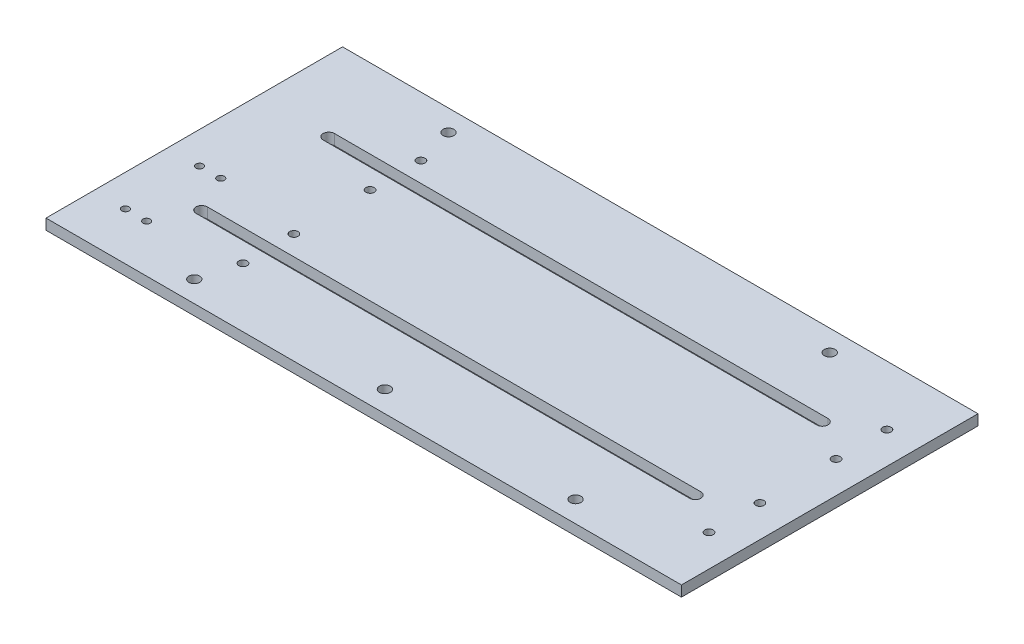
from build123d import *

# Parameters (mm, degrees)
SKETCH1_W                  = 381
SKETCH1_H                  = 177.8
PLATE_DEPTH                = 6.35
SKETCH4_R                  = 3.2639
CHASSISMOUNTINGHOLES_DEPTH = 6.35
SKETCH5_R                  = 2.5019
LEADSCREWGUIDEMOUNTS_DEPTH = 6.35
SKETCH6_R                  = 2.15265
LEADSCREWMOTORMOUNT_DEPTH  = 6.35
SKETCH8_R                  = 3.2639
CUT_EXTRUDE2_DEPTH         = 7.35
CUT_EXTRUDE4_DEPTH         = 7.35


with BuildPart() as part:
    # Sketch1 → Plate (new body)
    with BuildSketch(Plane(origin=(0, 0, 0), x_dir=(1, 0, 0), z_dir=(0, 1, 0))):
        Rectangle(SKETCH1_W, SKETCH1_H)
    extrude(amount=PLATE_DEPTH)

    # Sketch4 → ChassisMountingHoles (cut)
    with BuildSketch(Plane.XZ):
        with Locations((0, 76.2)):
            Circle(SKETCH4_R)
        with Locations((-114.3, 76.2)):
            Circle(SKETCH4_R)
        with Locations((114.3, 76.2)):
            Circle(SKETCH4_R)
        with Locations((-114.3, -76.2)):
            Circle(SKETCH4_R)
        with Locations((114.3, -76.2)):
            Circle(SKETCH4_R)
    extrude(amount=-CHASSISMOUNTINGHOLES_DEPTH, mode=Mode.SUBTRACT)

    # Sketch5 → LeadScrewGuideMounts (cut)
    with BuildSketch(Plane.XZ):
        with Locations((171.45, 53.34)):
            Circle(SKETCH5_R)
        with Locations((171.45, 22.86)):
            Circle(SKETCH5_R)
        with Locations((-107.95, 53.34)):
            Circle(SKETCH5_R)
        with Locations((-107.95, 22.86)):
            Circle(SKETCH5_R)
        with Locations((171.45, -53.34)):
            Circle(SKETCH5_R)
        with Locations((171.45, -22.86)):
            Circle(SKETCH5_R)
        with Locations((-107.95, -22.86)):
            Circle(SKETCH5_R)
        with Locations((-107.95, -53.34)):
            Circle(SKETCH5_R)
    extrude(amount=-LEADSCREWGUIDEMOUNTS_DEPTH, mode=Mode.SUBTRACT)

    # Sketch6 → LeadScrewMotorMount (cut)
    with BuildSketch(Plane.XZ):
        with Locations((-171.45, 60.325)):
            Circle(SKETCH6_R)
        with Locations((-158.75, 60.325)):
            Circle(SKETCH6_R)
        with Locations((-171.45, 15.875)):
            Circle(SKETCH6_R)
        with Locations((-158.75, 15.875)):
            Circle(SKETCH6_R)
    extrude(amount=-LEADSCREWMOTORMOUNT_DEPTH, mode=Mode.SUBTRACT)

    # Sketch8 → Cut-Extrude2 (cut, through all)
    with BuildSketch(Plane.XZ):
        with Locations((-25.4, 38.1)):
            Circle(SKETCH8_R)
        with Locations((25.4, 38.1)):
            Circle(SKETCH8_R)
        with Locations((76.2, 38.1)):
            Circle(SKETCH8_R)
    extrude(amount=-CUT_EXTRUDE2_DEPTH, mode=Mode.SUBTRACT)

    # Sketch10 → Cut-Extrude4 (cut, through all)
    with BuildSketch(Plane.XZ):
        with BuildLine():
            Line((-25.4, 41.4782), (-147.955, 41.4782))
            ThreePointArc((-147.955, 41.4782), (-151.3332, 38.1), (-147.955, 34.7218))
            Line((-147.955, 34.7218), (147.955, 34.7218))
            ThreePointArc((147.955, 34.7218), (151.3332, 38.1), (147.955, 41.4782))
            Line((147.955, 41.4782), (0, 41.4782))
            Line((0, 41.4782), (-25.4, 41.4782))
        make_face()
    cut_extrude4 = extrude(amount=-CUT_EXTRUDE4_DEPTH, mode=Mode.SUBTRACT)

    # Mirror3: Cut-Extrude4 across plane
    add(cut_extrude4.mirror(Plane.XY), mode=Mode.SUBTRACT)


solid = part.part
